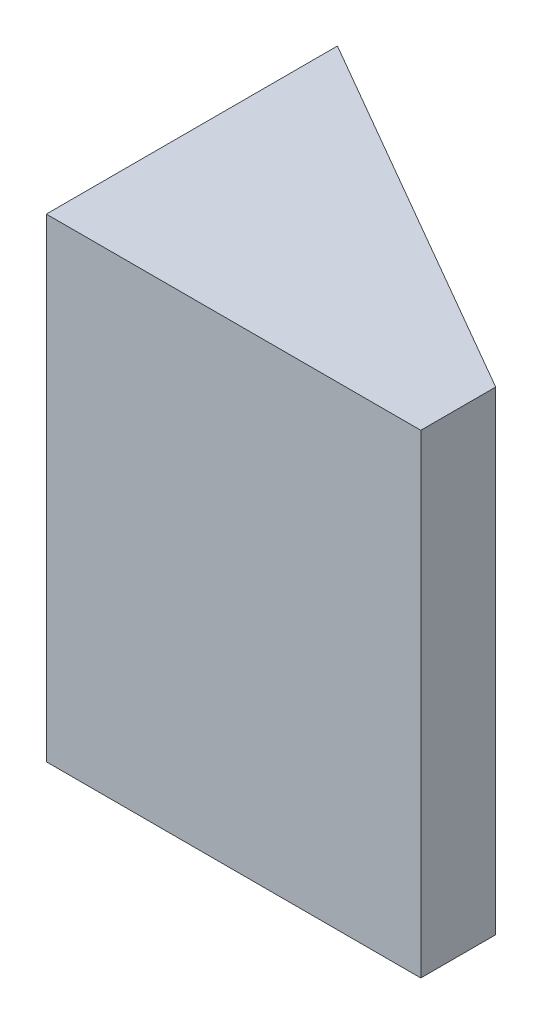
from build123d import *

# Parameters (mm, degrees)
SKIZZE1_W                       = 15
SKIZZE1_H                       = 19
AUFSATZ_LINEAR_AUSTRAGEN1_DEPTH = 3
AUFSATZ_LINEAR_AUSTRAGEN2_DEPTH = 19


with BuildPart() as part:
    # Skizze1 → Aufsatz-Linear austragen1 (new body)
    with BuildSketch(Plane.XY):
        Rectangle(SKIZZE1_W, SKIZZE1_H)
    extrude(amount=AUFSATZ_LINEAR_AUSTRAGEN1_DEPTH)

    # Skizze3 → Aufsatz-Linear austragen2 (add)
    with BuildSketch(Plane(origin=(0, 9.5, 0), x_dir=(1, 0, 0), z_dir=(0, 1, 0))):
        Polygon((-7.5, 0), (-7.5, 8.660254038), (7.5, 0), align=None)
    extrude(amount=-AUFSATZ_LINEAR_AUSTRAGEN2_DEPTH)


solid = part.part
